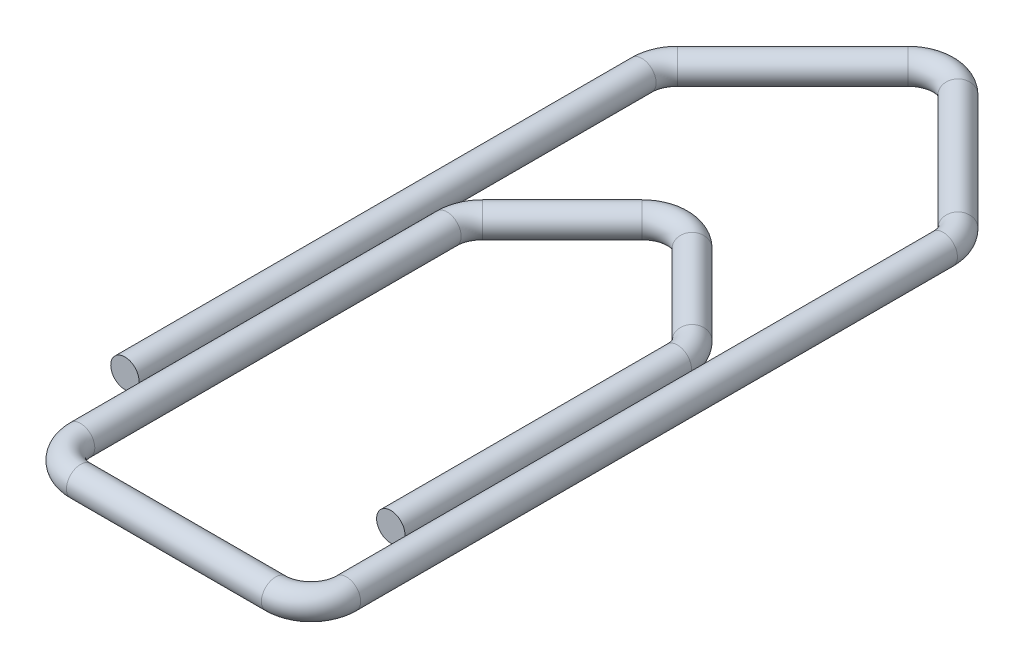
from build123d import *

# Parameters (mm, degrees)
SKETCH2_R = 0.8


with BuildPart() as part:
    # Sweep1: sweep along a path in Sketch1
    with BuildLine(Plane(origin=(0, 0, 0), x_dir=(1, 0, 0), z_dir=(0, 1, 0))) as sweep1_path:
        Line((0, 0), (0, 29.171572875))
        ThreePointArc((0, 29.171572875), (0.152240935, 29.93693974), (0.585786438, 30.585786438))
        Line((0.585786438, 30.585786438), (7.085786438, 37.085786438))
        ThreePointArc((7.085786438, 37.085786438), (8.5, 37.671572875), (9.914213562, 37.085786438))
        Line((9.914213562, 37.085786438), (16.414213562, 30.585786438))
        ThreePointArc((16.414213562, 30.585786438), (16.847759065, 29.93693974), (17, 29.171572875))
        Line((17, 29.171572875), (17, -4.5))
        ThreePointArc((17, -4.5), (16.414213562, -5.914213562), (15, -6.5))
        Line((15, -6.5), (4, -6.5))
        ThreePointArc((4, -6.5), (2.585786438, -5.914213562), (2, -4.5))
        Line((2, -4.5), (2, 16.171572875))
        ThreePointArc((2, 16.171572875), (2.152240935, 16.93693974), (2.585786438, 17.585786438))
        Line((2.585786438, 17.585786438), (7.085786438, 22.085786438))
        ThreePointArc((7.085786438, 22.085786438), (8.5, 22.671572875), (9.914213562, 22.085786438))
        Line((9.914213562, 22.085786438), (14.414213562, 17.585786438))
        ThreePointArc((14.414213562, 17.585786438), (14.847759065, 16.93693974), (15, 16.171572875))
        Line((15, 16.171572875), (15, 0))
    # Sketch2 → Sweep1 (sweep)
    with BuildSketch(Plane.XY):
        Circle(SKETCH2_R)
    sweep(path=sweep1_path.line)


solid = part.part
